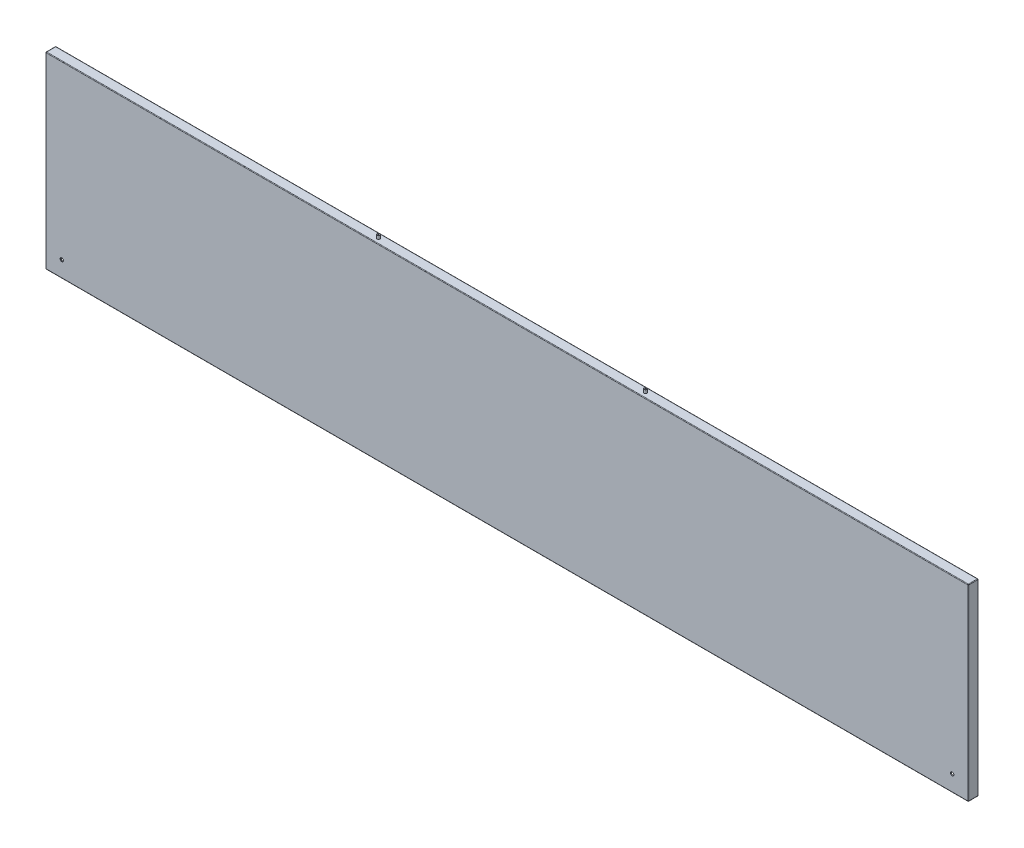
from build123d import *

# Parameters (mm, degrees)
SKETCH_1_W          = 1658
SKETCH_1_H          = 338
EXTRUDE_1_DEPTH     = 1.5
SKETCH_2_W          = 1658
SKETCH_2_H          = 338
SKETCH_2_W_2        = 1655
SKETCH_2_H_2        = 335
EXTRUDE_2_DEPTH     = 15
SKETCH_3_W          = 1658
SKETCH_3_H          = 338
SKETCH_3_W_2        = 1638
SKETCH_3_H_2        = 318
EXTRUDE_3_DEPTH     = 1.5
SKETCH_5_R          = 2.5
SKETCH_5_R_2        = 1
EXTRUDE_4_DEPTH     = 6
SKETCH_6_R          = 3
CUT_EXTRUDE_1_DEPTH = 19
FILLET_1_R          = 1


with BuildPart() as part:
    # 草图1 → 凸台-拉伸1 (new body)
    with BuildSketch(Plane.XY):
        Rectangle(SKETCH_1_W, SKETCH_1_H)
    extrude(amount=EXTRUDE_1_DEPTH)

    # 草图2 → 凸台-拉伸2 (add)
    with BuildSketch(Plane(origin=(0, 0, 0), x_dir=(-1, 0, 0), z_dir=(0, 0, -1))):
        Rectangle(SKETCH_2_W, SKETCH_2_H)
        Rectangle(SKETCH_2_W_2, SKETCH_2_H_2, mode=Mode.SUBTRACT)
    extrude(amount=EXTRUDE_2_DEPTH)

    # 草图3 → 凸台-拉伸3 (add)
    with BuildSketch(Plane(origin=(0, 0, -15), x_dir=(-1, 0, 0), z_dir=(0, 0, -1))):
        Rectangle(SKETCH_3_W, SKETCH_3_H)
        Rectangle(SKETCH_3_W_2, SKETCH_3_H_2, mode=Mode.SUBTRACT)
    extrude(amount=EXTRUDE_3_DEPTH)

    # 草图5 → 凸台-拉伸4 (add)
    with BuildSketch(Plane(origin=(0, 169, 0), x_dir=(1, 0, 0), z_dir=(0, 1, 0))):
        with Locations((240, 7.5)):
            Circle(SKETCH_5_R)
        with Locations((240, 7.5)):
            Circle(SKETCH_5_R_2, mode=Mode.SUBTRACT)
        with Locations((-240, 7.5)):
            Circle(SKETCH_5_R)
        with Locations((-240, 7.5)):
            Circle(SKETCH_5_R_2, mode=Mode.SUBTRACT)
    extrude(amount=EXTRUDE_4_DEPTH)

    # 草图6 → 切除-拉伸1 (cut, through all)
    with BuildSketch(Plane.XY.offset(1.5)):
        with Locations((-800, -140)):
            Circle(SKETCH_6_R)
        with Locations((800, -140)):
            Circle(SKETCH_6_R)
    extrude(amount=-CUT_EXTRUDE_1_DEPTH, mode=Mode.SUBTRACT)

    # 圆角1
    fillet_1_edges = [part.edges().sort_by_distance(p)[0] for p in [
        (829, 0, 1.5),
        (0, 169, 1.5),
        (-829, 0, -16.5),
        (0, 169, -16.5),
        (829, 0, -16.5),
        (0, -169, -16.5),
        (-829, 0, 1.5),
        (0, -169, 1.5),
        (-829, 169, -7.5),
        (829, 169, -7.5),
        (829, -169, -7.5),
        (-829, -169, -7.5),
    ]]
    fillet(fillet_1_edges, radius=FILLET_1_R)


solid = part.part
